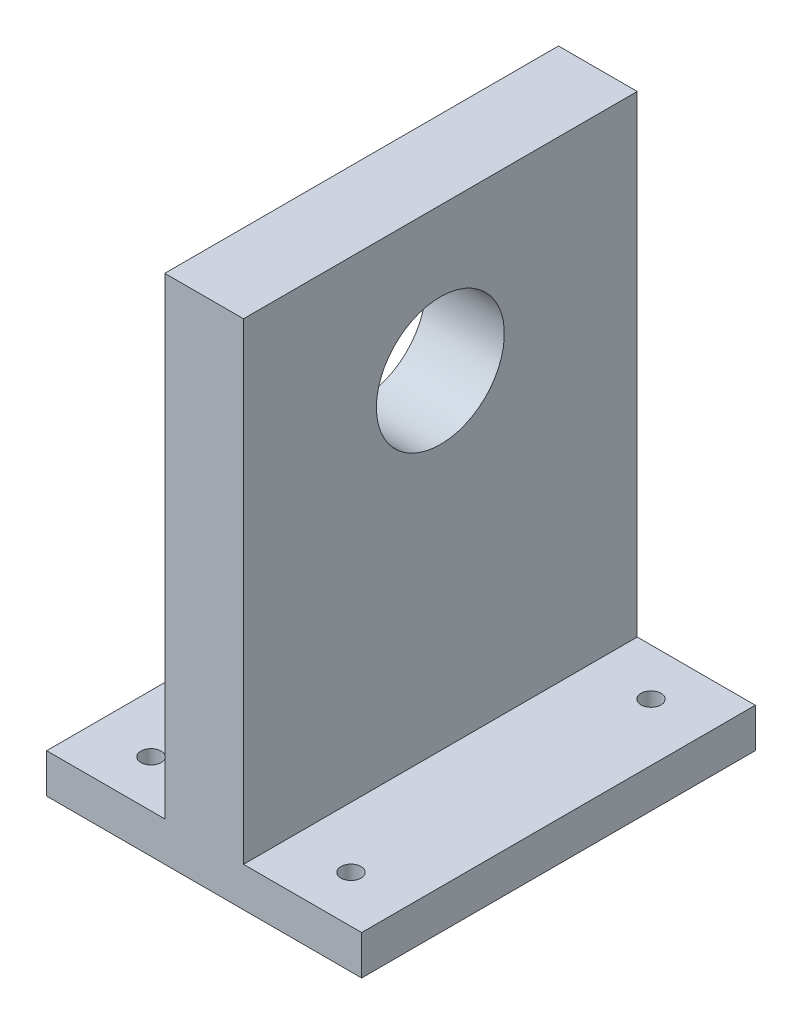
from build123d import *

# Parameters (mm, degrees)
SKETCH2_W           = 80
SKETCH2_H           = 100
BOSS_EXTRUDE1_DEPTH = 10
SKETCH3_W           = 20
SKETCH3_H           = 100
BOSS_EXTRUDE2_DEPTH = 120
SKETCH5_R           = 2.555
CUT_EXTRUDE2_DEPTH  = 55
SKETCH4_R           = 16.25
CUT_EXTRUDE4_DEPTH  = 45


with BuildPart() as part:
    # Sketch2 → Boss-Extrude1 (new body)
    with BuildSketch(Plane(origin=(0, 0, 0), x_dir=(1, 0, 0), z_dir=(0, 1, 0))):
        Rectangle(SKETCH2_W, SKETCH2_H)
    extrude(amount=BOSS_EXTRUDE1_DEPTH)

    # Sketch3 → Boss-Extrude2 (add)
    with BuildSketch(Plane(origin=(0, 10, 0), x_dir=(1, 0, 0), z_dir=(0, 1, 0))):
        Rectangle(SKETCH3_W, SKETCH3_H)
    extrude(amount=BOSS_EXTRUDE2_DEPTH)

    # Sketch5 → Cut-Extrude2 (cut)
    with BuildSketch(Plane.XZ):
        with Locations((-25.4, -38.1)):
            Circle(SKETCH5_R)
        with Locations((25.4, -38.1)):
            Circle(SKETCH5_R)
        with Locations((-25.4, 38.1)):
            Circle(SKETCH5_R)
        with Locations((25.4, 38.1)):
            Circle(SKETCH5_R)
    extrude(amount=-CUT_EXTRUDE2_DEPTH, mode=Mode.SUBTRACT)

    # Sketch4 → Cut-Extrude4 (cut)
    with BuildSketch(Plane.ZY.offset(10)):
        with Locations((0, 93.587135628)):
            Circle(SKETCH4_R)
    extrude(amount=-CUT_EXTRUDE4_DEPTH, mode=Mode.SUBTRACT)


solid = part.part
